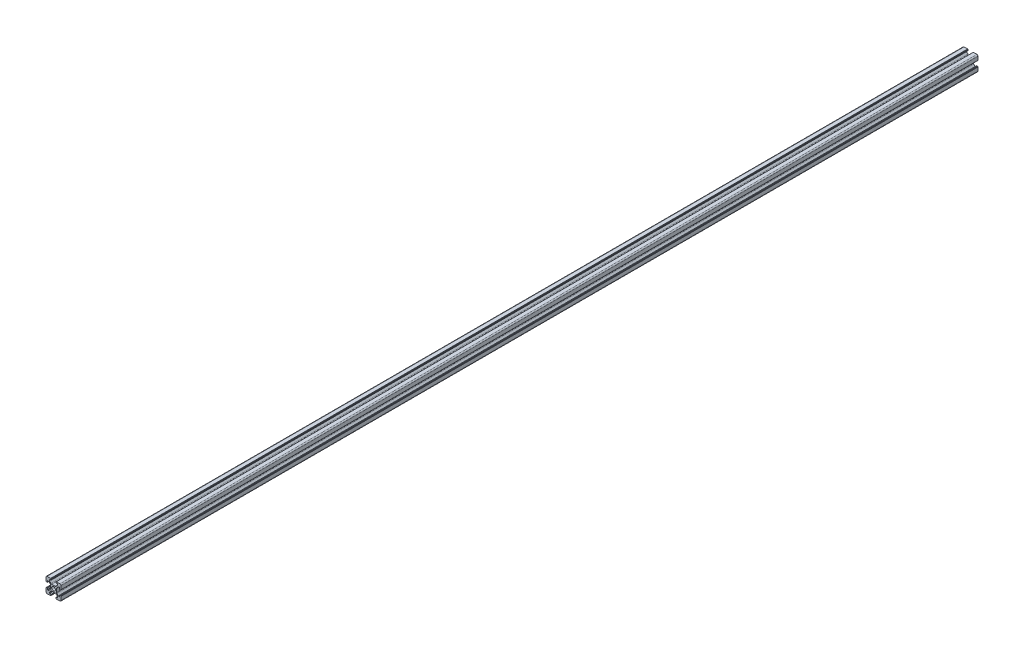
from build123d import *

# Parameters (mm, degrees)
SKETCH_1_R      = 2.5
EXTRUDE_1_DEPTH = 1220


with BuildPart() as part:
    # 草图1 → 凸台-拉伸1 (new body)
    with BuildSketch(Plane.XY):
        with BuildLine():
            Line((-8.502261885, -10.002261885), (-3.85, -10.002261885))
            ThreePointArc((-3.85, -10.002261885), (-3.673223305, -9.929038581), (-3.6, -9.752261885))
            Line((-3.6, -9.752261885), (-3.6, -9.502261885))
            Line((-3.6, -9.502261885), (-3.35, -9.502261885))
            ThreePointArc((-3.35, -9.502261885), (-3.173223305, -9.429038581), (-3.1, -9.252261885))
            Line((-3.1, -9.252261885), (-3.1, -8.45))
            ThreePointArc((-3.1, -8.45), (-3.173223305, -8.273223305), (-3.35, -8.2))
            Line((-3.35, -8.2), (-5.25, -8.2))
            ThreePointArc((-5.25, -8.2), (-5.426776695, -8.126776695), (-5.5, -7.95))
            Line((-5.5, -7.95), (-5.5, -6.664213562))
            ThreePointArc((-5.5, -6.664213562), (-5.480969883, -6.568542704), (-5.426776695, -6.487436867))
            Line((-5.426776695, -6.487436867), (-3.278679656, -4.339339828))
            ThreePointArc((-3.278679656, -4.339339828), (-2.792044633, -4.014180701), (-2.218019485, -3.9))
            Line((-2.218019485, -3.9), (2.218019485, -3.9))
            ThreePointArc((2.218019485, -3.9), (2.792044633, -4.014180701), (3.278679656, -4.339339828))
            Line((3.278679656, -4.339339828), (5.426776695, -6.487436867))
            ThreePointArc((5.426776695, -6.487436867), (5.480969883, -6.568542704), (5.5, -6.664213562))
            Line((5.5, -6.664213562), (5.5, -7.95))
            ThreePointArc((5.5, -7.95), (5.426776695, -8.126776695), (5.25, -8.2))
            Line((5.25, -8.2), (3.35, -8.2))
            ThreePointArc((3.35, -8.2), (3.173223305, -8.273223305), (3.1, -8.45))
            Line((3.1, -8.45), (3.1, -9.252261885))
            ThreePointArc((3.1, -9.252261885), (3.173223305, -9.429038581), (3.35, -9.502261885))
            Line((3.35, -9.502261885), (3.6, -9.502261885))
            Line((3.6, -9.502261885), (3.6, -9.752261885))
            ThreePointArc((3.6, -9.752261885), (3.673223305, -9.929038581), (3.85, -10.002261885))
            Line((3.85, -10.002261885), (8.502261885, -10.002261885))
            ThreePointArc((8.502261885, -10.002261885), (9.562922057, -9.562922057), (10.002261885, -8.502261885))
            Line((10.002261885, -8.502261885), (10.002261885, -3.85))
            ThreePointArc((10.002261885, -3.85), (9.929038581, -3.673223305), (9.752261885, -3.6))
            Line((9.752261885, -3.6), (9.502261885, -3.6))
            Line((9.502261885, -3.6), (9.502261885, -3.35))
            ThreePointArc((9.502261885, -3.35), (9.429038581, -3.173223305), (9.252261885, -3.1))
            Line((9.252261885, -3.1), (8.45, -3.1))
            ThreePointArc((8.45, -3.1), (8.273223305, -3.173223305), (8.2, -3.35))
            Line((8.2, -3.35), (8.2, -5.25))
            ThreePointArc((8.2, -5.25), (8.126776695, -5.426776695), (7.95, -5.5))
            Line((7.95, -5.5), (6.664213562, -5.5))
            ThreePointArc((6.664213562, -5.5), (6.568542704, -5.480969883), (6.487436867, -5.426776695))
            Line((6.487436867, -5.426776695), (4.339339828, -3.278679656))
            ThreePointArc((4.339339828, -3.278679656), (4.014180701, -2.792044633), (3.9, -2.218019485))
            Line((3.9, -2.218019485), (3.9, 2.218019485))
            ThreePointArc((3.9, 2.218019485), (4.014180701, 2.792044633), (4.339339828, 3.278679656))
            Line((4.339339828, 3.278679656), (6.487436867, 5.426776695))
            ThreePointArc((6.487436867, 5.426776695), (6.568542704, 5.480969883), (6.664213562, 5.5))
            Line((6.664213562, 5.5), (7.95, 5.5))
            ThreePointArc((7.95, 5.5), (8.126776695, 5.426776695), (8.2, 5.25))
            Line((8.2, 5.25), (8.2, 3.35))
            ThreePointArc((8.2, 3.35), (8.273223305, 3.173223305), (8.45, 3.1))
            Line((8.45, 3.1), (9.252261885, 3.1))
            ThreePointArc((9.252261885, 3.1), (9.429038581, 3.173223305), (9.502261885, 3.35))
            Line((9.502261885, 3.35), (9.502261885, 3.6))
            Line((9.502261885, 3.6), (9.752261885, 3.6))
            ThreePointArc((9.752261885, 3.6), (9.929038581, 3.673223305), (10.002261885, 3.85))
            Line((10.002261885, 3.85), (10.002261885, 8.502261885))
            ThreePointArc((10.002261885, 8.502261885), (9.562922057, 9.562922057), (8.502261885, 10.002261885))
            Line((8.502261885, 10.002261885), (3.85, 10.002261885))
            ThreePointArc((3.85, 10.002261885), (3.673223305, 9.929038581), (3.6, 9.752261885))
            Line((3.6, 9.752261885), (3.6, 9.502261885))
            Line((3.6, 9.502261885), (3.35, 9.502261885))
            ThreePointArc((3.35, 9.502261885), (3.173223305, 9.429038581), (3.1, 9.252261885))
            Line((3.1, 9.252261885), (3.1, 8.45))
            ThreePointArc((3.1, 8.45), (3.173223305, 8.273223305), (3.35, 8.2))
            Line((3.35, 8.2), (5.25, 8.2))
            ThreePointArc((5.25, 8.2), (5.426776695, 8.126776695), (5.5, 7.95))
            Line((5.5, 7.95), (5.5, 6.664213562))
            ThreePointArc((5.5, 6.664213562), (5.480969883, 6.568542704), (5.426776695, 6.487436867))
            Line((5.426776695, 6.487436867), (3.278679656, 4.339339828))
            ThreePointArc((3.278679656, 4.339339828), (2.792044633, 4.014180701), (2.218019485, 3.9))
            Line((2.218019485, 3.9), (-2.218019485, 3.9))
            ThreePointArc((-2.218019485, 3.9), (-2.792044633, 4.014180701), (-3.278679656, 4.339339828))
            Line((-3.278679656, 4.339339828), (-5.426776695, 6.487436867))
            ThreePointArc((-5.426776695, 6.487436867), (-5.480969883, 6.568542704), (-5.5, 6.664213562))
            Line((-5.5, 6.664213562), (-5.5, 7.95))
            ThreePointArc((-5.5, 7.95), (-5.426776695, 8.126776695), (-5.25, 8.2))
            Line((-5.25, 8.2), (-3.35, 8.2))
            ThreePointArc((-3.35, 8.2), (-3.173223305, 8.273223305), (-3.1, 8.45))
            Line((-3.1, 8.45), (-3.1, 9.252261885))
            ThreePointArc((-3.1, 9.252261885), (-3.173223305, 9.429038581), (-3.35, 9.502261885))
            Line((-3.35, 9.502261885), (-3.6, 9.502261885))
            Line((-3.6, 9.502261885), (-3.6, 9.752261885))
            ThreePointArc((-3.6, 9.752261885), (-3.673223305, 9.929038581), (-3.85, 10.002261885))
            Line((-3.85, 10.002261885), (-8.502261885, 10.002261885))
            ThreePointArc((-8.502261885, 10.002261885), (-9.562922057, 9.562922057), (-10.002261885, 8.502261885))
            Line((-10.002261885, 8.502261885), (-10.002261885, 3.85))
            ThreePointArc((-10.002261885, 3.85), (-9.929038581, 3.673223305), (-9.752261885, 3.6))
            Line((-9.752261885, 3.6), (-9.502261885, 3.6))
            Line((-9.502261885, 3.6), (-9.502261885, 3.35))
            ThreePointArc((-9.502261885, 3.35), (-9.429038581, 3.173223305), (-9.252261885, 3.1))
            Line((-9.252261885, 3.1), (-8.45, 3.1))
            ThreePointArc((-8.45, 3.1), (-8.273223305, 3.173223305), (-8.2, 3.35))
            Line((-8.2, 3.35), (-8.2, 5.25))
            ThreePointArc((-8.2, 5.25), (-8.126776695, 5.426776695), (-7.95, 5.5))
            Line((-7.95, 5.5), (-6.664213562, 5.5))
            ThreePointArc((-6.664213562, 5.5), (-6.568542704, 5.480969883), (-6.487436867, 5.426776695))
            Line((-6.487436867, 5.426776695), (-4.339339828, 3.278679656))
            ThreePointArc((-4.339339828, 3.278679656), (-4.014180701, 2.792044633), (-3.9, 2.218019485))
            Line((-3.9, 2.218019485), (-3.9, -2.218019485))
            ThreePointArc((-3.9, -2.218019485), (-4.014180701, -2.792044633), (-4.339339828, -3.278679656))
            Line((-4.339339828, -3.278679656), (-6.487436867, -5.426776695))
            ThreePointArc((-6.487436867, -5.426776695), (-6.568542704, -5.480969883), (-6.664213562, -5.5))
            Line((-6.664213562, -5.5), (-7.95, -5.5))
            ThreePointArc((-7.95, -5.5), (-8.126776695, -5.426776695), (-8.2, -5.25))
            Line((-8.2, -5.25), (-8.2, -3.35))
            ThreePointArc((-8.2, -3.35), (-8.273223305, -3.173223305), (-8.45, -3.1))
            Line((-8.45, -3.1), (-9.252261885, -3.1))
            ThreePointArc((-9.252261885, -3.1), (-9.429038581, -3.173223305), (-9.502261885, -3.35))
            Line((-9.502261885, -3.35), (-9.502261885, -3.6))
            Line((-9.502261885, -3.6), (-9.752261885, -3.6))
            ThreePointArc((-9.752261885, -3.6), (-9.929038581, -3.673223305), (-10.002261885, -3.85))
            Line((-10.002261885, -3.85), (-10.002261885, -8.502261885))
            ThreePointArc((-10.002261885, -8.502261885), (-9.562922057, -9.562922057), (-8.502261885, -10.002261885))
        make_face()
        Circle(SKETCH_1_R, mode=Mode.SUBTRACT)
    extrude(amount=EXTRUDE_1_DEPTH)


solid = part.part
